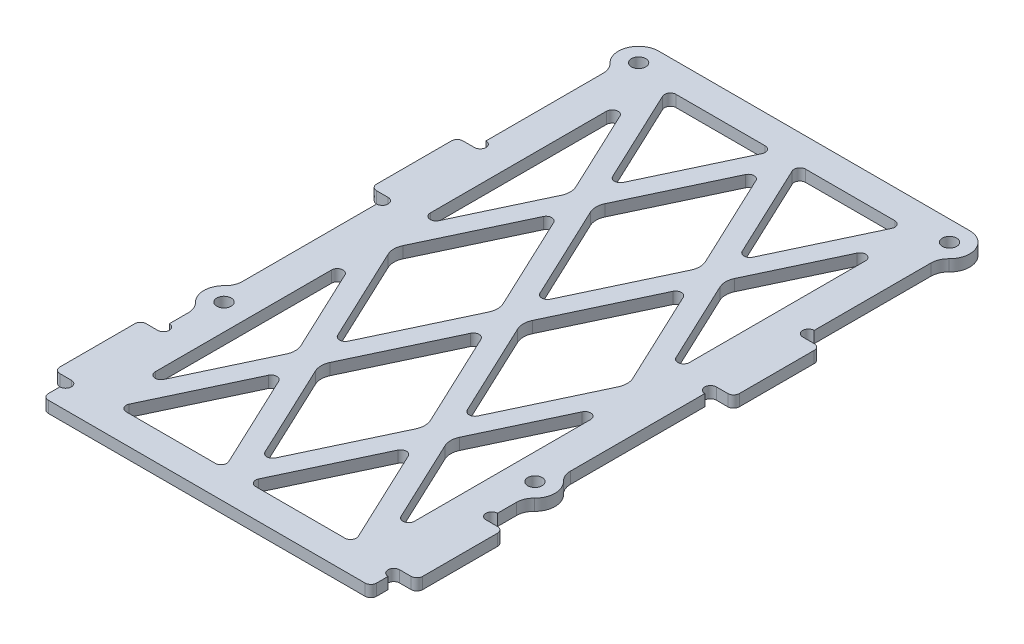
from build123d import *

# Parameters (mm, degrees)
SKETCH_1_R          = 1.25
EXTRUDE_1_DEPTH     = 2
SKETCH_2_R          = 1
SKETCH_2_W          = 45
SKETCH_2_H          = 95.5
CUT_EXTRUDE_1_DEPTH = 74.159073258
EXTRUDE_1_2_DEPTH   = 2
FILLET_1_R          = 1
FILLET_2_R          = 1
FILLET_3_R          = 3


with BuildPart() as part:
    # 草图1 → Extrude 1 (new body)
    with BuildSketch(Plane(origin=(0, 0, 0), x_dir=(1, 0, 0), z_dir=(0, 1, 0))):
        with BuildLine():
            Line((-28.5, 31.30958424), (-28.5, 9))
            Line((-28.5, 9), (-31.5, 9))
            Line((-31.5, 9), (-31.5, -6))
            Line((-31.5, -6), (-28.5, -6))
            Line((-28.5, -6), (-28.5, -31.30958424))
            ThreePointArc((-28.5, -31.30958424), (-28.740401367, -32.486281051), (-29.423076923, -33.474391514))
            ThreePointArc((-29.423076923, -33.474391514), (-30.5, -36), (-29.423076923, -38.525608486))
            ThreePointArc((-29.423076923, -38.525608486), (-28.740401367, -39.513718949), (-28.5, -40.69041576))
            Line((-28.5, -40.69041576), (-28.5, -46))
            Line((-28.5, -46), (-31.5, -46))
            Line((-31.5, -46), (-31.5, -61))
            Line((-31.5, -61), (-28.5, -61))
            Line((-28.5, -61), (-28.5, -66))
            Line((-28.5, -66), (28.5, -66))
            Line((28.5, -66), (28.5, -61))
            Line((28.5, -61), (31.5, -61))
            Line((31.5, -61), (31.5, -46))
            Line((31.5, -46), (28.5, -46))
            Line((28.5, -46), (28.5, -40.69041576))
            ThreePointArc((28.5, -40.69041576), (28.740401367, -39.513718949), (29.423076923, -38.525608486))
            ThreePointArc((29.423076923, -38.525608486), (30.5, -36), (29.423076923, -33.474391514))
            ThreePointArc((29.423076923, -33.474391514), (28.740401367, -32.486281051), (28.5, -31.30958424))
            Line((28.5, -31.30958424), (28.5, -6))
            Line((28.5, -6), (31.5, -6))
            Line((31.5, -6), (31.5, 9))
            Line((31.5, 9), (28.5, 9))
            Line((28.5, 9), (28.5, 31.30958424))
            ThreePointArc((28.5, 31.30958424), (28.740401367, 32.486281051), (29.423076923, 33.474391514))
            ThreePointArc((29.423076923, 33.474391514), (30.247278068, 37.305827381), (27, 39.5))
            Line((27, 39.5), (-27, 39.5))
            ThreePointArc((-27, 39.5), (-30.247278068, 37.305827381), (-29.423076923, 33.474391514))
            ThreePointArc((-29.423076923, 33.474391514), (-28.740401367, 32.486281051), (-28.5, 31.30958424))
        make_face()
        with Locations(Location((-27, 36, 0), (0, 0, 270))):
            Circle(SKETCH_1_R, mode=Mode.SUBTRACT)
        with Locations(Location((-27, -36, 0), (0, 0, 90))):
            Circle(SKETCH_1_R, mode=Mode.SUBTRACT)
        with Locations(Location((27, 36, 0), (0, 0, 90))):
            Circle(SKETCH_1_R, mode=Mode.SUBTRACT)
        with Locations(Location((27, -36, 0), (0, 0, 270))):
            Circle(SKETCH_1_R, mode=Mode.SUBTRACT)
    extrude(amount=EXTRUDE_1_DEPTH)

    # 草图2 → 切除-拉伸1 (cut, through all)
    with BuildSketch(Plane(origin=(0, 2, 0), x_dir=(1, 0, 0), z_dir=(0, 1, 0))):
        with Locations((-28.5, -45)):
            Circle(SKETCH_2_R)
        with Locations((-28.5, -62)):
            Circle(SKETCH_2_R)
        with Locations((28.5, -62)):
            Circle(SKETCH_2_R)
        with Locations((28.5, -45)):
            Circle(SKETCH_2_R)
        with Locations((-28.5, 10)):
            Circle(SKETCH_2_R)
        with Locations((-28.5, -7)):
            Circle(SKETCH_2_R)
        with Locations((28.5, -7)):
            Circle(SKETCH_2_R)
        with Locations((28.5, 10)):
            Circle(SKETCH_2_R)
        with Locations((0, -13.25)):
            Rectangle(SKETCH_2_W, SKETCH_2_H)
    extrude(amount=-CUT_EXTRUDE_1_DEPTH, mode=Mode.SUBTRACT)

    # 草图3 → Extrude 1 2 (add)
    # profile 1 of 3: a face of its own
    with BuildSketch(Plane(origin=(0, 2, 0), x_dir=(1, 0, 0), z_dir=(0, 1, 0))):
        Polygon((-24.083056856, 33.754056979), (20.916943144, -61.745943021), (24.083056856, -60.254056979), (-20.916943144, 35.245943021), align=None)
    # profile 2 of 3: a face of its own
    with BuildSketch(Plane(origin=(0, 2, 0), x_dir=(1, 0, 0), z_dir=(0, 1, 0))):
        Polygon((-20.916943144, -61.745943021), (24.083056856, 33.754056979), (20.916943144, 35.245943021), (-24.083056856, -60.254056979), align=None)
    # profile 3 of 3: a face of its own
    with BuildSketch(Plane(origin=(0, 2, 0), x_dir=(1, 0, 0), z_dir=(0, 1, 0))):
        Polygon((0, 38.60554146), (-24.434548332, -13.25), (0, -65.10554146), (24.434548332, -13.25), align=None)
        Polygon((0, 30.39445854), (-20.565451668, -13.25), (0, -56.89445854), (20.565451668, -13.25), align=None, mode=Mode.SUBTRACT)
    extrude(amount=-EXTRUDE_1_2_DEPTH)

    # 圆角1
    fillet_1_edges = [part.edges().sort_by_distance(p)[0] for p in [
        (31.5, 1, -9),
        (31.5, 1, 6),
        (31.5, 1, 46),
        (31.5, 1, 61),
        (28.5, 1, 66),
        (-28.5, 1, 66),
        (-31.5, 1, 61),
        (-31.5, 1, 46),
        (-31.5, 1, 6),
        (-31.5, 1, -9),
    ]]
    fillet(fillet_1_edges, radius=FILLET_1_R)

    # 圆角2
    fillet_2_edges = [part.edges().sort_by_distance(p)[0] for p in [
        (-1.934548332, 1, 61),
        (1.934548332, 1, 61),
        (-20.565451668, 1, 61),
        (20.565451668, 1, 61),
        (22.5, 1, 17.35554146),
        (22.5, 1, 9.14445854),
        (22.5, 1, -30.39445854),
        (22.5, 1, 56.89445854),
        (-1.934548332, 1, -34.5),
        (1.934548332, 1, -34.5),
        (20.565451668, 1, -34.5),
        (-20.565451668, 1, -34.5),
        (-22.5, 1, 17.35554146),
        (-22.5, 1, 9.14445854),
        (-22.5, 1, 56.89445854),
        (-22.5, 1, -30.39445854),
        (-11.25, 1, -14.73054146),
        (11.25, 1, -14.73054146),
        (11.25, 1, 41.23054146),
        (-11.25, 1, 41.23054146),
        (-11.25, 1, -6.51945854),
        (0, 1, -30.39445854),
        (11.25, 1, 33.01945854),
        (0, 1, 9.14445854),
        (11.25, 1, -6.51945854),
        (0, 1, 17.35554146),
        (-11.25, 1, 33.01945854),
        (0, 1, 56.89445854),
    ]]
    fillet(fillet_2_edges, radius=FILLET_2_R)

    # 圆角3
    fillet_3_edges = [part.edges().sort_by_distance(p)[0] for p in [
        (-13.184548332, 1, 37.125),
        (-13.184548332, 1, -10.625),
        (13.184548332, 1, 37.125),
        (13.184548332, 1, -10.625),
        (-1.934548332, 1, 13.25),
        (9.315451668, 1, 37.125),
        (1.934548332, 1, 13.25),
        (9.315451668, 1, -10.625),
        (20.565451668, 1, 13.25),
        (-9.315451668, 1, -10.625),
        (-9.315451668, 1, 37.125),
        (-20.565451668, 1, 13.25),
    ]]
    fillet(fillet_3_edges, radius=FILLET_3_R)


solid = part.part
